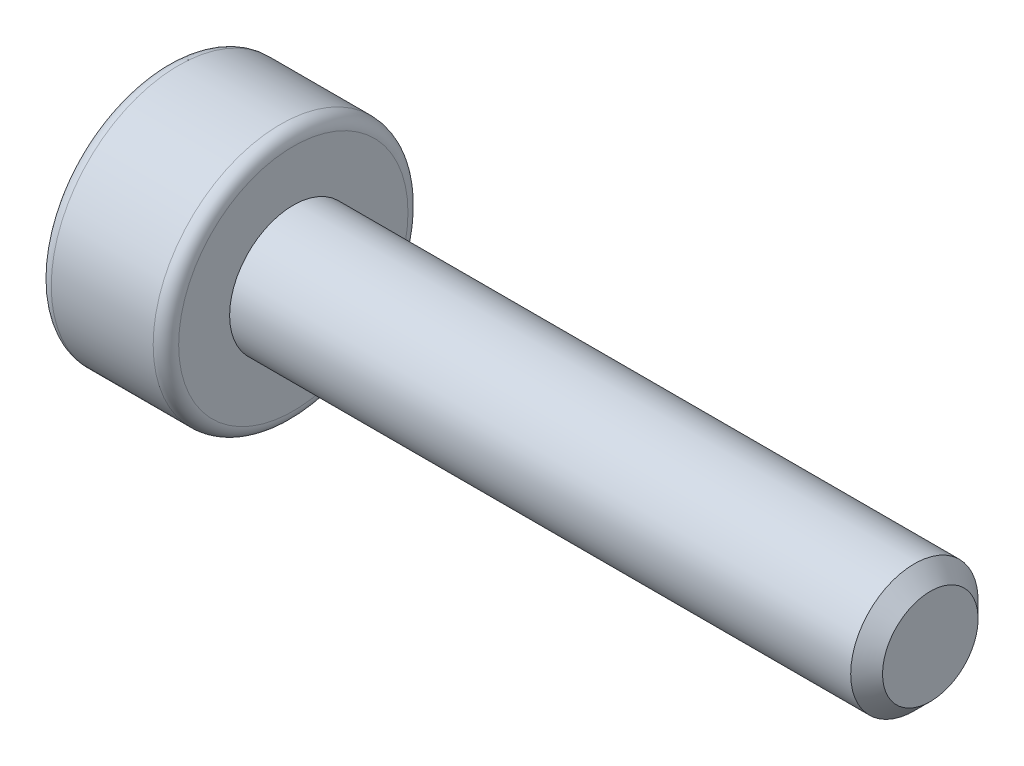
from build123d import *

# Parameters (mm, degrees)
CUT_EXTRUDE1_DEPTH = 0.8


with BuildPart() as part:
    # Sketch2 → Revolve1 (revolve)
    with BuildSketch(Plane.XY):
        with BuildLine():
            Line((0, 0), (0, 1.8))
            ThreePointArc((0, 1.8), (0.058578644, 1.941421356), (0.2, 2))
            Line((0.2, 2), (1.8, 2))
            ThreePointArc((1.8, 2), (1.941421356, 1.941421356), (2, 1.8))
            Line((2, 1.8), (2, 1))
            Line((2, 1), (11.75, 1))
            Line((11.75, 1), (12, 0.75))
            Line((12, 0.75), (12, 0))
            Line((12, 0), (0, 0))
        make_face()
    revolve(axis=Axis((-2.281841559, 0, 0), (1, 0, 0)))

    # Sketch3 → Cut-Extrude1 (cut)
    with BuildSketch(Plane.ZY):
        Polygon((0.433012702, -0.75), (0.866025404, 0), (0.433012702, 0.75), (-0.433012702, 0.75), (-0.866025404, 0), (-0.433012702, -0.75), align=None)
    extrude(amount=-CUT_EXTRUDE1_DEPTH, mode=Mode.SUBTRACT)


solid = part.part
